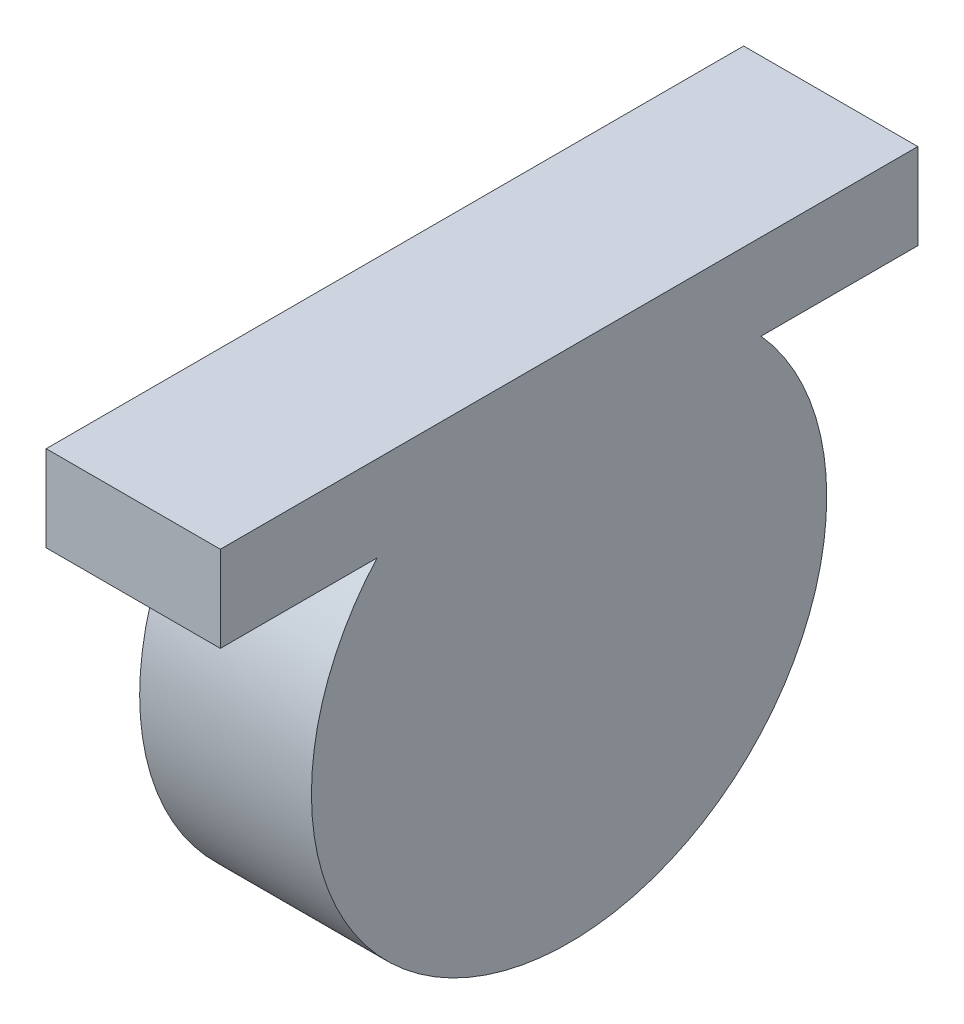
from build123d import *

# Parameters (mm, degrees)
SKETCH3_W           = 25.753050404
SKETCH3_H           = 103.137359271
BOSS_EXTRUDE1_DEPTH = 12.7
SKETCH4_R           = 38.1
BOSS_EXTRUDE2_DEPTH = 25.4


with BuildPart() as part:
    # Sketch3 → Boss-Extrude1 (new body)
    with BuildSketch(Plane(origin=(0, 717.636591226, 0), x_dir=(-1, 0, 0), z_dir=(0, -1, 0))):
        with Locations((-511.2749233, -660.547915429)):
            Rectangle(SKETCH3_W, SKETCH3_H)
    extrude(amount=BOSS_EXTRUDE1_DEPTH)

    # Sketch4 → Boss-Extrude2 (add)
    with BuildSketch(Plane(origin=(524.151448502, 0, 0), x_dir=(0, 0, -1), z_dir=(1, 0, 0))):
        with Locations((-660.547915428, 679.536591226)):
            Circle(SKETCH4_R)
    extrude(amount=-BOSS_EXTRUDE2_DEPTH)


solid = part.part
